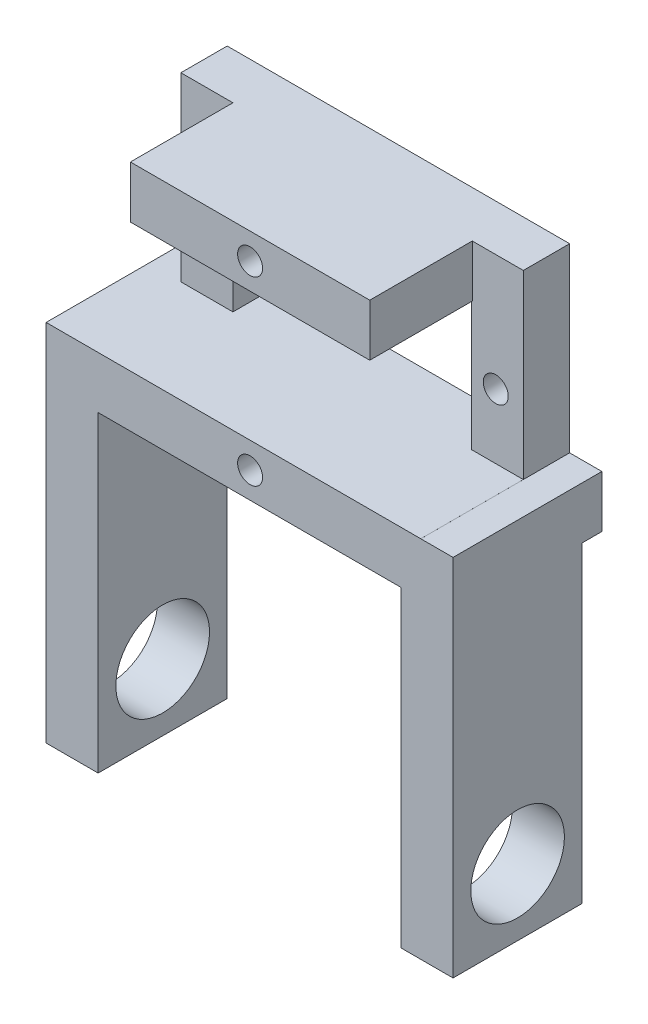
from build123d import *

# Parameters (mm, degrees)
SKETCH1_W           = 32.9
SKETCH1_H           = 22.4
BOSS_EXTRUDE1_DEPTH = 5
SKETCH2_R           = 1.2
SKETCH2_W           = 22.9
SKETCH2_H           = 12.4
CUT_EXTRUDE2_DEPTH  = 5
SKETCH3_W           = 22.996888994
SKETCH3_H           = 5
BOSS_EXTRUDE2_DEPTH = 12.3
SKETCH4_R           = 1.2
CUT_EXTRUDE3_DEPTH  = 5
SKETCH6_W           = 5
SKETCH6_H           = 5
SKETCH6_W_2         = 4.903111006
BOSS_EXTRUDE3_DEPTH = 12.3
SKETCH8_W           = 17.3
SKETCH8_H           = 4.998204887
BOSS_EXTRUDE4_DEPTH = 3.1
SKETCH9_W           = 17.3
SKETCH9_H           = 5
BOSS_EXTRUDE5_DEPTH = 3.1
SKETCH18_W          = 5
SKETCH18_H          = 12.4
BOSS_EXTRUDE7_DEPTH = 30
SKETCH19_R          = 4.5
CUT_EXTRUDE6_DEPTH  = 30
SKETCH20_R          = 4.5
CUT_EXTRUDE7_DEPTH  = 30
SKETCH10_W          = 5
SKETCH10_H          = 12.4
BOSS_EXTRUDE6_DEPTH = 30
SKETCH21_R          = 4.5
CUT_EXTRUDE8_DEPTH  = 10
SKETCH22_R          = 4.5
CUT_EXTRUDE9_DEPTH  = 10
CUT_EXTRUDE10_DEPTH = 3
SKETCH25_W          = 2.45
SKETCH25_H          = 22.4
SKETCH25_W_2        = 0.55
CUT_EXTRUDE11_DEPTH = 40.1


with BuildPart() as part:
    # Sketch1 → Boss-Extrude1 (new body)
    with BuildSketch(Plane.XY):
        Rectangle(SKETCH1_W, SKETCH1_H)
    extrude(amount=BOSS_EXTRUDE1_DEPTH)

    # Sketch2 → Cut-Extrude2 (cut)
    with BuildSketch(Plane.XY.offset(5)):
        with Locations((13.8, 0)):
            Circle(SKETCH2_R)
        with Locations((-13.8, 0)):
            Circle(SKETCH2_R)
        Rectangle(SKETCH2_W, SKETCH2_H)
    extrude(amount=-CUT_EXTRUDE2_DEPTH, mode=Mode.SUBTRACT)

    # Sketch3 → Boss-Extrude2 (add)
    with BuildSketch(Plane.XY.offset(5)):
        with Locations((0.048444497, 8.7)):
            Rectangle(SKETCH3_W, SKETCH3_H)
        with Locations((0.048444497, -8.7)):
            Rectangle(SKETCH3_W, SKETCH3_H)
    extrude(amount=BOSS_EXTRUDE2_DEPTH)

    # Sketch4 → Cut-Extrude3 (cut)
    with BuildSketch(Plane.XY.offset(17.3)):
        with Locations((0.048444497, 8.7)):
            Circle(SKETCH4_R)
        with Locations((0.048444497, -8.7)):
            Circle(SKETCH4_R)
    extrude(amount=-CUT_EXTRUDE3_DEPTH, mode=Mode.SUBTRACT)

    # Sketch6 → Boss-Extrude3 (add)
    with BuildSketch(Plane.XY.offset(5)):
        with Locations((-13.95, -8.7)):
            Rectangle(SKETCH6_W, SKETCH6_H)
        with Locations((13.998444497, -8.7)):
            Rectangle(SKETCH6_W_2, SKETCH6_H)
    extrude(amount=BOSS_EXTRUDE3_DEPTH)

    # Sketch8 → Boss-Extrude4 (add)
    with BuildSketch(Plane(origin=(16.45, 0, 0), x_dir=(0, 0, -1), z_dir=(1, 0, 0))):
        with Locations((-8.65, -8.700897557)):
            Rectangle(SKETCH8_W, SKETCH8_H)
    extrude(amount=BOSS_EXTRUDE4_DEPTH)

    # Sketch9 → Boss-Extrude5 (add)
    with BuildSketch(Plane.ZY.offset(16.45)):
        with Locations((8.65, -8.7)):
            Rectangle(SKETCH9_W, SKETCH9_H)
    extrude(amount=BOSS_EXTRUDE5_DEPTH)

    # Sketch18 → Boss-Extrude7 (add)
    with BuildSketch(Plane.XZ.offset(11.2)):
        with Locations((-17.05, 8.65)):
            Rectangle(SKETCH18_W, SKETCH18_H)
        with Locations((17.05, 8.65)):
            Rectangle(SKETCH18_W, SKETCH18_H)
    extrude(amount=BOSS_EXTRUDE7_DEPTH)

    # Sketch19 → Cut-Extrude6 (cut)
    with BuildSketch(Plane.ZY.offset(19.55)):
        with Locations((8.65, -34.8)):
            Circle(SKETCH19_R)
    extrude(amount=-CUT_EXTRUDE6_DEPTH, mode=Mode.SUBTRACT)

    # Sketch20 → Cut-Extrude7 (cut)
    with BuildSketch(Plane(origin=(19.55, 0, 0), x_dir=(0, 0, -1), z_dir=(1, 0, 0))):
        with Locations((-8.65, -34.8)):
            Circle(SKETCH20_R)
    extrude(amount=-CUT_EXTRUDE7_DEPTH, mode=Mode.SUBTRACT)

    # Sketch10 → Boss-Extrude6 (add)
    with BuildSketch(Plane.XZ.offset(11.2)):
        with Locations((17.05, 8.65)):
            Rectangle(SKETCH10_W, SKETCH10_H)
        with Locations((-17.05, 8.65)):
            Rectangle(SKETCH10_W, SKETCH10_H)
    extrude(amount=BOSS_EXTRUDE6_DEPTH)

    # Sketch21 → Cut-Extrude8 (cut)
    with BuildSketch(Plane(origin=(19.55, 0, 0), x_dir=(0, 0, -1), z_dir=(1, 0, 0))):
        with Locations((-8.65, -34.8)):
            Circle(SKETCH21_R)
    extrude(amount=-CUT_EXTRUDE8_DEPTH, mode=Mode.SUBTRACT)

    # Sketch22 → Cut-Extrude9 (cut)
    with BuildSketch(Plane(origin=(-14.55, 0, 0), x_dir=(0, 0, -1), z_dir=(1, 0, 0))):
        with Locations((-8.65, -34.8)):
            Circle(SKETCH22_R)
    extrude(amount=-CUT_EXTRUDE9_DEPTH, mode=Mode.SUBTRACT)

    # Sketch23 → Cut-Extrude10 (cut)
    with BuildSketch(Plane.ZY.offset(19.55)):
        with BuildLine():
            Line((5.65, -22.3), (4.674239456, -32.692079676))
            ThreePointArc((4.674239456, -32.692079676), (8.65, -30.3), (12.625760544, -32.692079676))
            Line((12.625760544, -32.692079676), (11.65, -22.3))
            ThreePointArc((11.65, -22.3), (8.65, -19.3), (5.65, -22.3))
        make_face()
    extrude(amount=-CUT_EXTRUDE10_DEPTH, mode=Mode.SUBTRACT)

    # Sketch25 → Cut-Extrude11 (cut, through all)
    with BuildSketch(Plane.ZY.offset(19.55)):
        with Locations((16.075, 0)):
            Rectangle(SKETCH25_W, SKETCH25_H)
        with Locations((0.275, 0)):
            Rectangle(SKETCH25_W_2, SKETCH25_H)
    extrude(amount=-CUT_EXTRUDE11_DEPTH, mode=Mode.SUBTRACT)


solid = part.part
